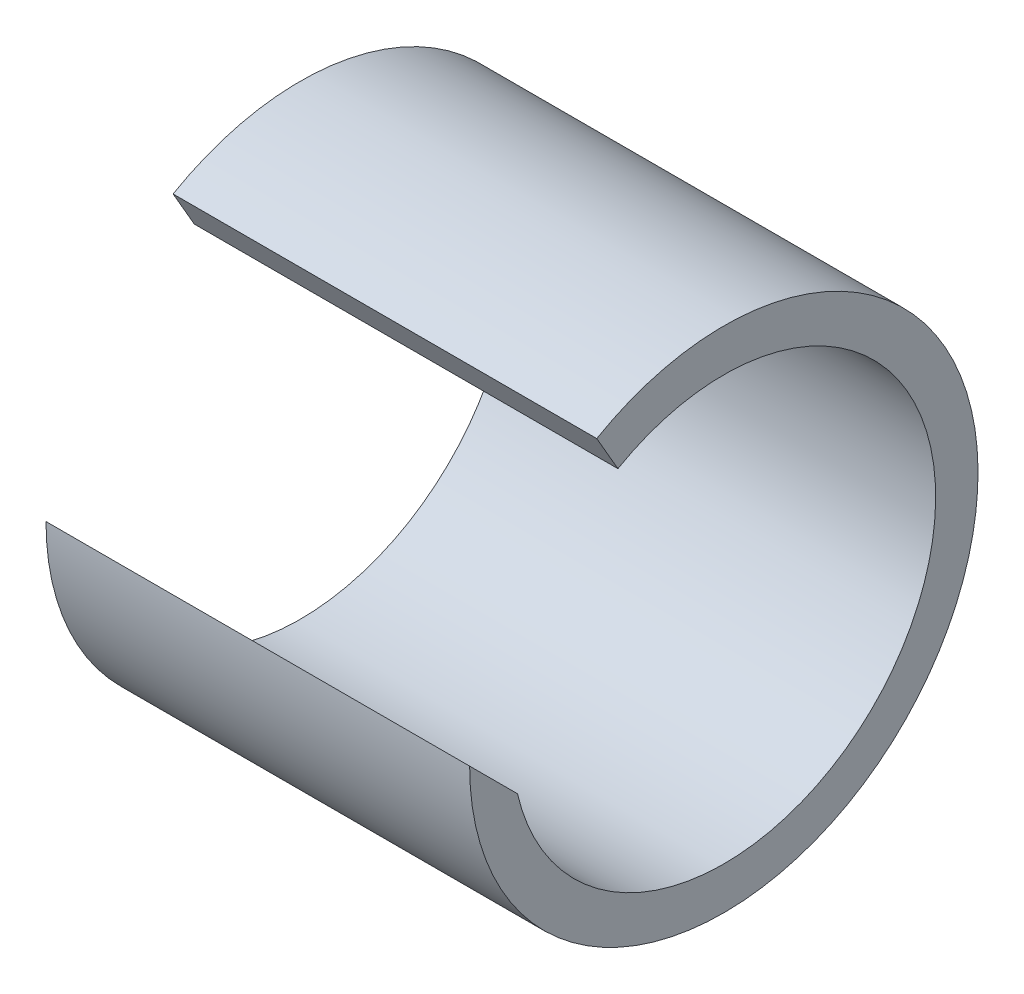
from build123d import *

# Parameters (mm, degrees)
SKETCH1_R           = 19.05
SKETCH1_R_2         = 15.875
BOSS_EXTRUDE1_DEPTH = 31.75
CUT_EXTRUDE2_DEPTH  = 32.75
CUT_EXTRUDE3_DEPTH  = 32.75


with BuildPart() as part:
    # Sketch1 → Boss-Extrude1 (new body)
    with BuildSketch(Plane(origin=(0, 0, 0), x_dir=(0, 0, -1), z_dir=(1, 0, 0))):
        Circle(SKETCH1_R)
        Circle(SKETCH1_R_2, mode=Mode.SUBTRACT)
    extrude(amount=BOSS_EXTRUDE1_DEPTH)

    # Sketch2 → Cut-Extrude2 (cut, through all)
    with BuildSketch(Plane(origin=(31.75, 0, 0), x_dir=(0, 0, -1), z_dir=(1, 0, 0))):
        with BuildLine():
            Line((-15.875, 0), (-19.05, 0))
            ThreePointArc((-19.05, 0), (-16.497783942, 9.525), (-9.525, 16.497783942))
            Line((-9.525, 16.497783942), (-7.9375, 13.748153285))
            ThreePointArc((-7.9375, 13.748153285), (-13.748153285, 7.9375), (-15.875, 0))
        make_face()
    extrude(amount=-CUT_EXTRUDE2_DEPTH, mode=Mode.SUBTRACT)

    # Sketch3 → Cut-Extrude3 (cut, through all)
    with BuildSketch(Plane(origin=(31.75, 0, 0), x_dir=(0, 0, -1), z_dir=(1, 0, 0))):
        with BuildLine():
            Line((-19.05, 0), (-15.875, 0))
            ThreePointArc((-15.875, 0), (-15.772137022, -1.804250192), (-15.464881102, -3.585118898))
            Line((-15.464881102, -3.585118898), (-19.05, 0))
        make_face()
    extrude(amount=-CUT_EXTRUDE3_DEPTH, mode=Mode.SUBTRACT)


solid = part.part
